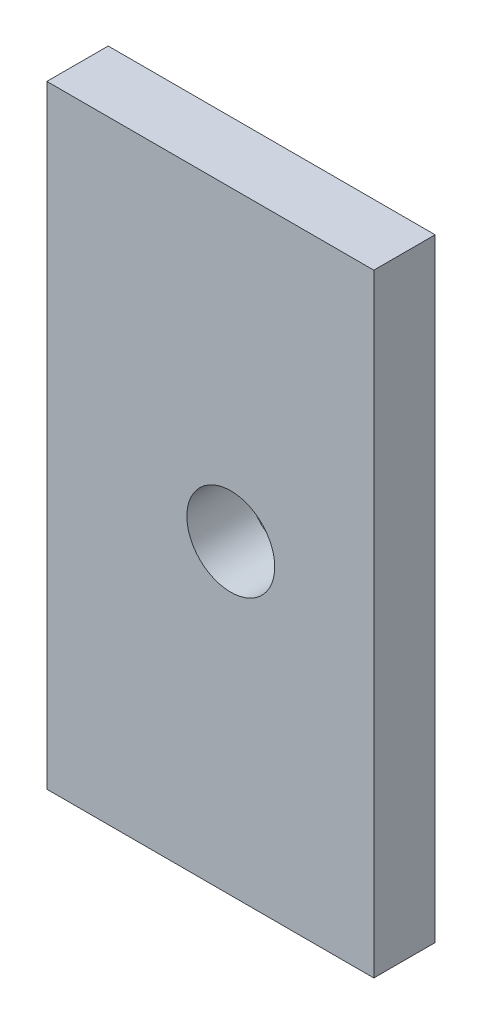
from build123d import *

# Parameters (mm, degrees)
SKETCH1_W                = 16
SKETCH1_H                = 30
BOSS_EXTRUDE1_DEPTH      = 3
M4_CLEARANCE_HOLE1_D     = 4.3
M4_CLEARANCE_HOLE1_DEPTH = 100
M4_CLEARANCE_HOLE1_TIP   = 1.291850331


with BuildPart() as part:
    # Sketch1 → Boss-Extrude1 (new body)
    with BuildSketch(Plane.XY):
        with Locations((-8, 15)):
            Rectangle(SKETCH1_W, SKETCH1_H)
    extrude(amount=BOSS_EXTRUDE1_DEPTH)

    # M4 Clearance Hole1
    with Locations(Plane.XY.offset(3)):
        with Locations((-7, 15)):
            Hole(M4_CLEARANCE_HOLE1_D / 2, depth=M4_CLEARANCE_HOLE1_DEPTH)
            with Locations((0, 0, -(M4_CLEARANCE_HOLE1_DEPTH + M4_CLEARANCE_HOLE1_TIP / 2))):  # 118° drill point
                Cone(0, M4_CLEARANCE_HOLE1_D / 2, M4_CLEARANCE_HOLE1_TIP, mode=Mode.SUBTRACT)


solid = part.part
